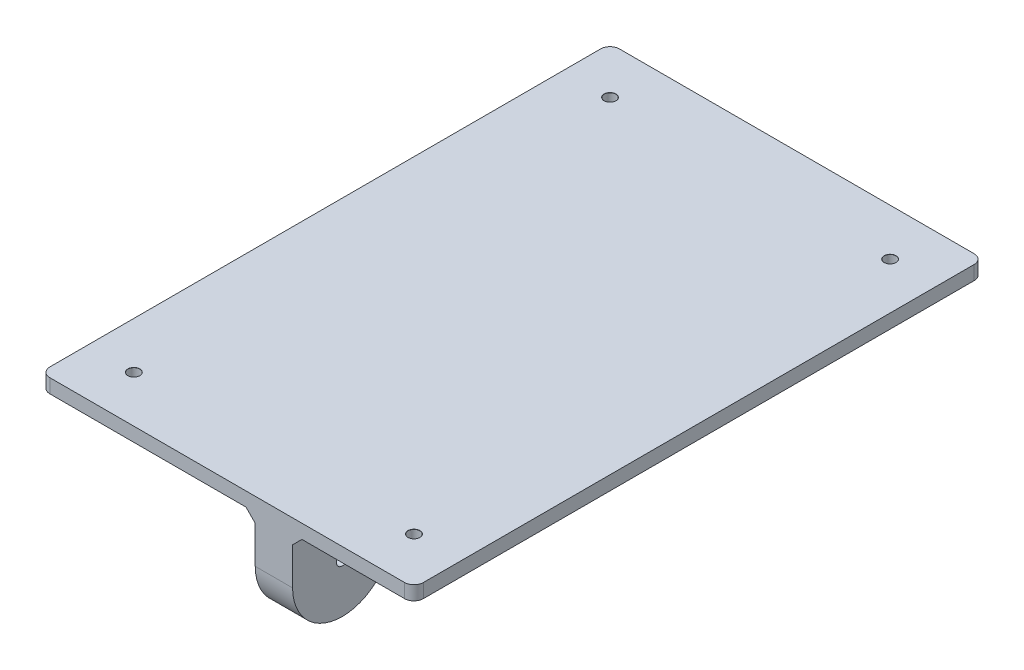
from build123d import *

# Parameters (mm, degrees)
SKETCH1_W                       = 80
SKETCH1_H                       = 122
BOSS_EXTRUDE1_DEPTH             = 3
BOSS_EXTRUDE2_DEPTH             = 8
SKETCH4_R                       = 6.45
CUT_EXTRUDE1_DEPTH              = 6
CHAMFER1_SIZE                   = 2
FILLET1_R                       = 2
F_2_5MM_DOWEL_HOLE1_D           = 2.5
F_2_5MM_DOWEL_HOLE1_DEPTH       = 5
F_2_5MM_DOWEL_HOLE1_CSINK_D     = 2.55
F_2_5MM_DOWEL_HOLE1_CSINK_ANGLE = 90
F_2_5MM_DOWEL_HOLE1_TIP         = 0.751075774
F_2_5MM_DOWEL_HOLE2_D           = 2.5
F_2_5MM_DOWEL_HOLE2_DEPTH       = 5
F_2_5MM_DOWEL_HOLE2_CSINK_D     = 2.55
F_2_5MM_DOWEL_HOLE2_CSINK_ANGLE = 90
F_2_5MM_DOWEL_HOLE2_TIP         = 0.751075774


with BuildPart() as part:
    # Sketch1 → Boss-Extrude1 (new body)
    with BuildSketch(Plane(origin=(0, 0, 0), x_dir=(1, 0, 0), z_dir=(0, 1, 0))):
        Rectangle(SKETCH1_W, SKETCH1_H)
    extrude(amount=BOSS_EXTRUDE1_DEPTH)

    # Sketch3 → Boss-Extrude2 (add)
    with BuildSketch(Plane(origin=(6, 0, 0), x_dir=(0, 0, -1), z_dir=(1, 0, 0))):
        with BuildLine():
            Line((-61, 0), (-61, -10))
            ThreePointArc((-61, -10), (-50.36, -20.64), (-39.72, -10))
            Line((-39.72, -10), (-39.72, 0))
            Line((-39.72, 0), (-61, 0))
        make_face()
        with BuildLine():
            Line((61, 0), (61, -10))
            ThreePointArc((61, -10), (50.36, -20.64), (39.72, -10))
            Line((39.72, -10), (39.72, 0))
            Line((39.72, 0), (61, 0))
        make_face()
    extrude(amount=BOSS_EXTRUDE2_DEPTH)

    # Sketch4 → Cut-Extrude1 (cut)
    with BuildSketch(Plane.ZY.offset(-6)):
        with Locations((-50.36, -10)):
            Circle(SKETCH4_R)
        with Locations((50.36, -10)):
            Circle(SKETCH4_R)
    extrude(amount=-CUT_EXTRUDE1_DEPTH, mode=Mode.SUBTRACT)

    # Chamfer1
    chamfer1_edges = [part.edges().sort_by_distance(p)[0] for p in [
        (6, 0, 50.36),
        (10, 0, 39.72),
        (14, 0, 50.36),
        (6, 0, -50.36),
        (10, 0, -39.72),
        (14, 0, -50.36),
    ]]
    chamfer(chamfer1_edges, length=CHAMFER1_SIZE)

    # Fillet1
    fillet1_edges = [part.edges().sort_by_distance(p)[0] for p in [
        (40, 1.5, 61),
        (-40, 1.5, 61),
        (-40, 1.5, -61),
        (40, 1.5, -61),
    ]]
    fillet(fillet1_edges, radius=FILLET1_R)

    # Ø2.5mm Dowel Hole1
    with Locations(Plane(origin=(0, 3, 0), x_dir=(1, 0, 0), z_dir=(0, 1, 0))):
        with Locations((-30, 51), (-30, -51), (30, -51), (30, 51)):
            CounterSinkHole(F_2_5MM_DOWEL_HOLE1_D / 2, F_2_5MM_DOWEL_HOLE1_CSINK_D / 2, depth=F_2_5MM_DOWEL_HOLE1_DEPTH, counter_sink_angle=F_2_5MM_DOWEL_HOLE1_CSINK_ANGLE)
            with Locations((0, 0, -(F_2_5MM_DOWEL_HOLE1_DEPTH + F_2_5MM_DOWEL_HOLE1_TIP / 2))):  # 118° drill point
                Cone(0, F_2_5MM_DOWEL_HOLE1_D / 2, F_2_5MM_DOWEL_HOLE1_TIP, mode=Mode.SUBTRACT)

    # Ø2.5mm Dowel Hole2
    with Locations(Plane.ZY.offset(-12)):
        with Locations((-50.36, -10), (50.36, -10)):
            CounterSinkHole(F_2_5MM_DOWEL_HOLE2_D / 2, F_2_5MM_DOWEL_HOLE2_CSINK_D / 2, depth=F_2_5MM_DOWEL_HOLE2_DEPTH, counter_sink_angle=F_2_5MM_DOWEL_HOLE2_CSINK_ANGLE)
            with Locations((0, 0, -(F_2_5MM_DOWEL_HOLE2_DEPTH + F_2_5MM_DOWEL_HOLE2_TIP / 2))):  # 118° drill point
                Cone(0, F_2_5MM_DOWEL_HOLE2_D / 2, F_2_5MM_DOWEL_HOLE2_TIP, mode=Mode.SUBTRACT)


solid = part.part
